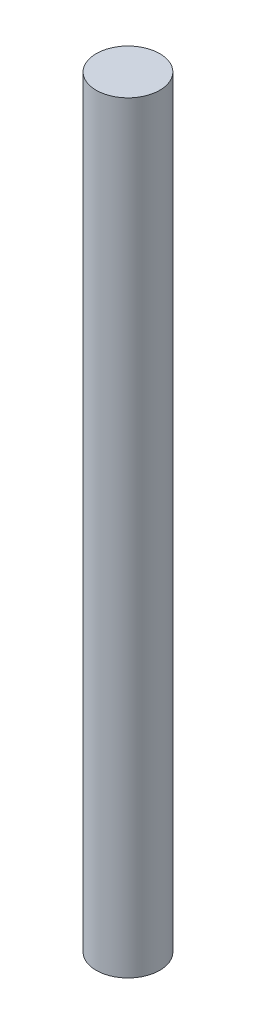
from build123d import *

# Parameters (mm, degrees)
SKETCH1_R           = 12.7
BOSS_EXTRUDE1_DEPTH = 304.8


with BuildPart() as part:
    # Sketch1 → Boss-Extrude1 (new body)
    with BuildSketch(Plane(origin=(0, 0, 0), x_dir=(1, 0, 0), z_dir=(0, 1, 0))):
        Circle(SKETCH1_R)
    extrude(amount=BOSS_EXTRUDE1_DEPTH)


solid = part.part
